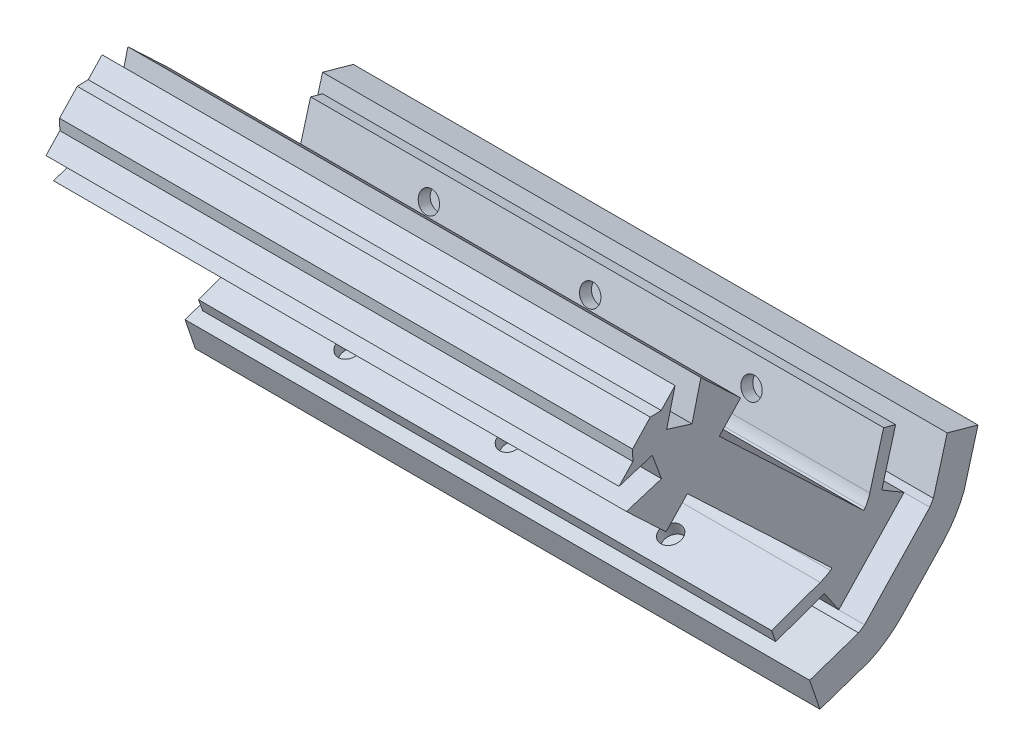
from build123d import *

# Parameters (mm, degrees)
SALIENTE_EXTRUIR1_DEPTH  = 111
CROQUIS2_W               = 111
CROQUIS2_H               = 6.192779451
SALIENTE_EXTRUIR2_DEPTH  = 10
CROQUIS3_W               = 111
CROQUIS3_H               = 2.409514801
SALIENTE_EXTRUIR3_DEPTH  = 10
CROQUIS4_W               = 111
CROQUIS4_H               = 2.398640609
SALIENTE_EXTRUIR4_DEPTH  = 10
CROQUIS5_W               = 111
CROQUIS5_H               = 6.192779451
SALIENTE_EXTRUIR5_DEPTH  = 10
CROQUIS6_W               = 111
CROQUIS6_H               = 5
SALIENTE_EXTRUIR6_DEPTH  = 4.321315
CROQUIS7_W               = 111
CROQUIS7_H               = 5
SALIENTE_EXTRUIR7_DEPTH  = 4.278447
CROQUIS8_W               = 111
CROQUIS8_H               = 9
SALIENTE_EXTRUIR8_DEPTH  = 55
CROQUIS9_R               = 2
CORTAR_EXTRUIR1_DEPTH    = 16
CROQUIS10_R              = 4
CORTAR_EXTRUIR2_DEPTH    = 4
CROQUIS11_R              = 2
CORTAR_EXTRUIR3_DEPTH    = 15
CROQUIS12_R              = 4
CORTAR_EXTRUIR4_DEPTH    = 4
SALIENTE_EXTRUIR9_DEPTH  = 5
SALIENTE_EXTRUIR11_DEPTH = 5
CHAFL_N1_SIZE            = 2
CROQUIS17_W              = 111
CROQUIS17_H              = 2.5
CORTAR_EXTRUIR5_DEPTH    = 1
CROQUIS18_W              = 111
CROQUIS18_H              = 2.5
CORTAR_EXTRUIR6_DEPTH    = 1
SALIENTE_EXTRUIR13_DEPTH = 111
CORTAR_EXTRUIR7_DEPTH    = 111


with BuildPart() as part:
    # Croquis1 → Saliente-Extruir1 (new body)
    with BuildSketch(Plane(origin=(0, 0, 0), x_dir=(0, 0, -1), z_dir=(1, 0, 0))):
        with BuildLine():
            Line((7.281662572, 0.608509867), (5.132212893, 1.885171952))
            Line((5.132212893, 1.885171952), (2.982763214, 3.161834037))
            Line((2.982763214, 3.161834037), (5.189506733, 6.877213544))
            Line((5.189506733, 6.877213544), (2.867848216, 7.521933103))
            ThreePointArc((2.867848216, 7.521933103), (2.490196159, 6.4721221), (1.960989109, 5.489948939))
            Line((1.960989109, 5.489948939), (-4.770871258, -1.63199293))
            ThreePointArc((-4.770871258, -1.63199293), (-5.721710129, -2.215627798), (-6.748607586, -2.651753735))
            Line((-6.748607586, -2.651753735), (-5.938704572, -4.909525619))
            Line((-5.938704572, -4.909525619), (-2.388950365, -2.52114656))
            Line((-2.388950365, -2.52114656), (-0.993362777, -4.595353706))
            Line((-0.993362777, -4.595353706), (0.402224811, -6.669560852))
            Line((0.402224811, -6.669560852), (-4.197240467, -9.7642164))
            Line((-4.197240467, -9.7642164), (-4.309282935, -9.839601868))
            Line((-4.309282935, -9.839601868), (-2.319133534, -15.703885515))
            ThreePointArc((-2.319133534, -15.703885515), (1.153217714, -13.714536347), (4.172917336, -11.088484655))
            Line((4.172917336, -11.088484655), (11.905759692, -2.907558323))
            ThreePointArc((11.905759692, -2.907558323), (14.35773408, 0.255123277), (16.14854429, 3.83391247))
            Line((16.14854429, 3.83391247), (10.181567392, 5.490929075))
            Line((10.181567392, 5.490929075), (7.281662572, 0.608509867))
        make_face()
    extrude(amount=SALIENTE_EXTRUIR1_DEPTH)

    # Croquis2 → Saliente-Extruir2 (add)
    with BuildSketch(Plane(origin=(0, 7.722777916, -2.144598757), x_dir=(1, 0, 0), z_dir=(0, 0.963537769, -0.267572359))):
        with Locations((55.5, 11.437493615)):
            Rectangle(CROQUIS2_W, CROQUIS2_H)
    extrude(amount=SALIENTE_EXTRUIR2_DEPTH)

    # Croquis3 → Saliente-Extruir3 (add)
    with BuildSketch(Plane(origin=(0, 7.722777916, -2.144598757), x_dir=(1, 0, 0), z_dir=(0, 0.963537769, -0.267572359))):
        with Locations((55.5, 1.955376092)):
            Rectangle(CROQUIS3_W, CROQUIS3_H)
    extrude(amount=SALIENTE_EXTRUIR3_DEPTH)

    # Croquis4 → Saliente-Extruir4 (add)
    with BuildSketch(Plane(origin=(0, -0.571048753, 7.494993546), x_dir=(1, 0, 0), z_dir=(0, 0.337650839, -0.941271433))):
        with Locations((55.5, 3.409846311)):
            Rectangle(CROQUIS4_W, CROQUIS4_H)
    extrude(amount=-SALIENTE_EXTRUIR4_DEPTH)

    # Croquis5 → Saliente-Extruir5 (add)
    with BuildSketch(Plane(origin=(0, -0.440143301, 7.499157089), x_dir=(1, 0, 0), z_dir=(0, 0.321366103, -0.946955029))):
        with Locations((55.5, 13.022371717)):
            Rectangle(CROQUIS5_W, CROQUIS5_H)
    extrude(amount=-SALIENTE_EXTRUIR5_DEPTH)

    # Croquis6 → Saliente-Extruir6 (add)
    with BuildSketch(Plane(origin=(0, 3.646905534, -2.166073516), x_dir=(1, 0, 0), z_dir=(0, 0.859779871, -0.510664834))):
        with Locations((55.5, 3.44988232)):
            Rectangle(CROQUIS6_W, CROQUIS6_H)
    extrude(amount=SALIENTE_EXTRUIR6_DEPTH)

    # Croquis7 → Saliente-Extruir7 (add)
    with BuildSketch(Plane(origin=(0, 6.51296949, 8.467369412), x_dir=(1, 0, 0), z_dir=(0, 0.558235035, -0.829682858))):
        with Locations((55.5, 13.388637699)):
            Rectangle(CROQUIS7_W, CROQUIS7_H)
    extrude(amount=-SALIENTE_EXTRUIR7_DEPTH)

    # Croquis8 → Saliente-Extruir8 (add)
    with BuildSketch(Plane(origin=(0, 1.611575356, 1.704959012), x_dir=(1, 0, 0), z_dir=(0, 0.686924527, 0.726728762))):
        with Locations((55.5, 0.436755314)):
            Rectangle(CROQUIS8_W, CROQUIS8_H)
    extrude(amount=SALIENTE_EXTRUIR8_DEPTH)

    # Croquis9 → Cortar-Extruir1 (cut)
    with BuildSketch(Plane(origin=(0, -3.888865446, -14.003945532), x_dir=(-1, 0, 0), z_dir=(0, -0.267572359, -0.963537769))):
        with Locations((-86.75, 13.015023554)):
            Circle(CROQUIS9_R)
        with Locations((-55.5, 13.015023554)):
            Circle(CROQUIS9_R)
        with Locations((-24.25, 13.015023554)):
            Circle(CROQUIS9_R)
    extrude(amount=-CORTAR_EXTRUIR1_DEPTH, mode=Mode.SUBTRACT)

    # Croquis10 → Cortar-Extruir2 (cut)
    with BuildSketch(Plane(origin=(0, -3.888865446, -14.003945532), x_dir=(-1, 0, 0), z_dir=(0, -0.267572359, -0.963537769))):
        with Locations((-86.75, 13.015023554)):
            Circle(CROQUIS10_R)
        with Locations((-55.5, 13.015023554)):
            Circle(CROQUIS10_R)
        with Locations((-24.25, 13.015023554)):
            Circle(CROQUIS10_R)
    extrude(amount=-CORTAR_EXTRUIR2_DEPTH, mode=Mode.SUBTRACT)

    # Croquis11 → Cortar-Extruir3 (cut)
    with BuildSketch(Plane(origin=(0, -13.376291354, -4.539483394), x_dir=(1, 0, 0), z_dir=(0, -0.946955029, -0.321366103))):
        with Locations((55.5, 12.242811659)):
            Circle(CROQUIS11_R)
        with Locations((24.25, 12.242811659)):
            Circle(CROQUIS11_R)
        with Locations((86.75, 12.242811659)):
            Circle(CROQUIS11_R)
    extrude(amount=-CORTAR_EXTRUIR3_DEPTH, mode=Mode.SUBTRACT)

    # Croquis12 → Cortar-Extruir4 (cut)
    with BuildSketch(Plane(origin=(0, -13.376291354, -4.539483394), x_dir=(-1, 0, 0), z_dir=(0, -0.946955029, -0.321366103))):
        with Locations((-24.25, -12.242811659)):
            Circle(CROQUIS12_R)
        with Locations((-55.5, -12.242811659)):
            Circle(CROQUIS12_R)
        with Locations((-86.75, -12.242811659)):
            Circle(CROQUIS12_R)
    extrude(amount=-CORTAR_EXTRUIR4_DEPTH, mode=Mode.SUBTRACT)

    # Croquis13 → Saliente-Extruir9 (add)
    with BuildSketch(Plane.ZY):
        with BuildLine():
            Line((-9.48840609, 4.323889374), (3.147529397, -9.057939911))
            Line((3.147529397, -9.057939911), (4.309282935, -9.839601868))
            Line((4.309282935, -9.839601868), (13.778833228, -13.053262902))
            Line((13.778833228, -13.053262902), (11.788683827, -18.917546549))
            Line((11.788683827, -18.917546549), (2.319133534, -15.703885515))
            ThreePointArc((2.319133534, -15.703885515), (-1.153217714, -13.714536347), (-4.172917336, -11.088484655))
            Line((-4.172917336, -11.088484655), (-11.905759692, -2.907558323))
            ThreePointArc((-11.905759692, -2.907558323), (-14.35773408, 0.255123277), (-16.14854429, 3.83391247))
            Line((-16.14854429, 3.83391247), (-18.824267877, 13.469290163))
            Line((-18.824267877, 13.469290163), (-12.857290979, 15.126306768))
            Line((-12.857290979, 15.126306768), (-10.181567392, 5.490929075))
            Line((-10.181567392, 5.490929075), (-9.48840609, 4.323889374))
        make_face()
    extrude(amount=SALIENTE_EXTRUIR9_DEPTH)

    # Croquis15 → Saliente-Extruir11 (add)
    with BuildSketch(Plane(origin=(111, 0, 0), x_dir=(0, 0, -1), z_dir=(1, 0, 0))):
        with BuildLine():
            Line((-3.147529397, -9.057939911), (9.48840609, 4.323889374))
            Line((9.48840609, 4.323889374), (10.181567392, 5.490929075))
            Line((10.181567392, 5.490929075), (12.857290979, 15.126306768))
            Line((12.857290979, 15.126306768), (18.824267877, 13.469290163))
            Line((18.824267877, 13.469290163), (16.14854429, 3.83391247))
            ThreePointArc((16.14854429, 3.83391247), (14.35773408, 0.255123277), (11.905759692, -2.907558323))
            Line((11.905759692, -2.907558323), (4.172917336, -11.088484655))
            ThreePointArc((4.172917336, -11.088484655), (1.153217714, -13.714536347), (-2.319133534, -15.703885515))
            Line((-2.319133534, -15.703885515), (-11.788683827, -18.917546549))
            Line((-11.788683827, -18.917546549), (-13.778833228, -13.053262902))
            Line((-13.778833228, -13.053262902), (-4.309282935, -9.839601868))
            Line((-4.309282935, -9.839601868), (-3.147529397, -9.057939911))
        make_face()
    extrude(amount=SALIENTE_EXTRUIR11_DEPTH)

    # Chaflán1
    chafl_n1_edges = [part.edges().sort_by_distance(p)[0] for p in [
        (55.5, 42.980106436, 38.283862622),
        (55.5, 36.439547576, 44.466183368),
    ]]
    chamfer(chafl_n1_edges, length=CHAFL_N1_SIZE)

    # Croquis17 → Cortar-Extruir5 (cut)
    with BuildSketch(Plane(origin=(0, 3.587682079, -3.391178311), x_dir=(1, 0, 0), z_dir=(0, 0.726728762, -0.686924527))):
        with Locations((55.5, -54.596073392)):
            Rectangle(CROQUIS17_W, CROQUIS17_H)
    extrude(amount=-CORTAR_EXTRUIR5_DEPTH, mode=Mode.SUBTRACT)

    # Croquis18 → Cortar-Extruir6 (cut)
    with BuildSketch(Plane(origin=(0, -2.952876781, 2.791142435), x_dir=(-1, 0, 0), z_dir=(0, -0.726728762, 0.686924527))):
        with Locations((-55.5, -54.596073392)):
            Rectangle(CROQUIS18_W, CROQUIS18_H)
    extrude(amount=-CORTAR_EXTRUIR6_DEPTH, mode=Mode.SUBTRACT)

    # Croquis19 → Saliente-Extruir13 (add)
    with BuildSketch(Plane.ZY):
        Polygon((37.537231743, 41.586355264), (33.072222315, 46.310092218), (22.171290882, 36.006224308), (36.596705955, 20.744920302), (47.497637388, 31.048788212), (43.032627961, 35.772525166), (43.092334313, 37.8930051), (39.657711677, 41.526648911), align=None)
    extrude(amount=-SALIENTE_EXTRUIR13_DEPTH)

    # Croquis20 → Cortar-Extruir7 (cut)
    with BuildSketch(Plane.ZY):
        Polygon((45.713483262, 32.936326171), (39.269105528, 34.936320207), (37.48465455, 30.110641878), (44.275491662, 28.003125173), (47.497637388, 31.048788212), align=None)
        Polygon((33.072222315, 46.310092218), (34.856376442, 44.422554259), (36.490580545, 37.875848411), (31.572137947, 36.36576264), (29.850076589, 43.264429179), align=None)
    extrude(amount=-CORTAR_EXTRUIR7_DEPTH, mode=Mode.SUBTRACT)


solid = part.part
